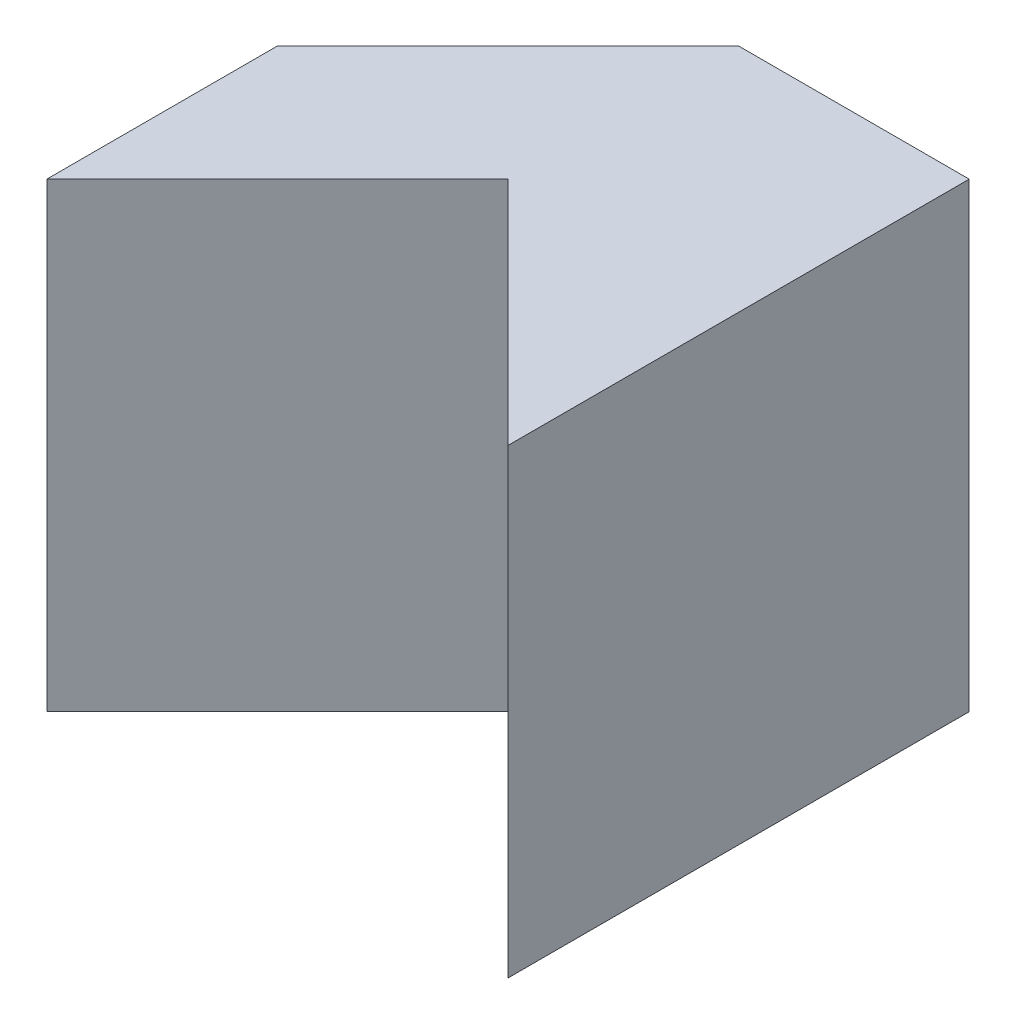
from build123d import *

# Parameters (mm, degrees)
SKETCH1_W           = 20
SKETCH1_H           = 20
BOSS_EXTRUDE1_DEPTH = 20
CUT_EXTRUDE1_DEPTH  = 20
CUT_EXTRUDE2_DEPTH  = 20


with BuildPart() as part:
    # Sketch1 → Boss-Extrude1 (new body)
    with BuildSketch(Plane.XY):
        with Locations((10, 10)):
            Rectangle(SKETCH1_W, SKETCH1_H)
    extrude(amount=BOSS_EXTRUDE1_DEPTH)

    # Sketch2 → Cut-Extrude1 (cut)
    with BuildSketch(Plane(origin=(0, 20, 0), x_dir=(1, 0, 0), z_dir=(0, 1, 0))):
        Polygon((0, 0), (10, 0), (0, -10), align=None)
    extrude(amount=-CUT_EXTRUDE1_DEPTH, mode=Mode.SUBTRACT)

    # Sketch3 → Cut-Extrude2 (cut)
    with BuildSketch(Plane(origin=(0, 20, 0), x_dir=(1, 0, 0), z_dir=(0, 1, 0))):
        Polygon((20, -20), (10, -10), (0, -20), align=None)
    extrude(amount=-CUT_EXTRUDE2_DEPTH, mode=Mode.SUBTRACT)


solid = part.part
